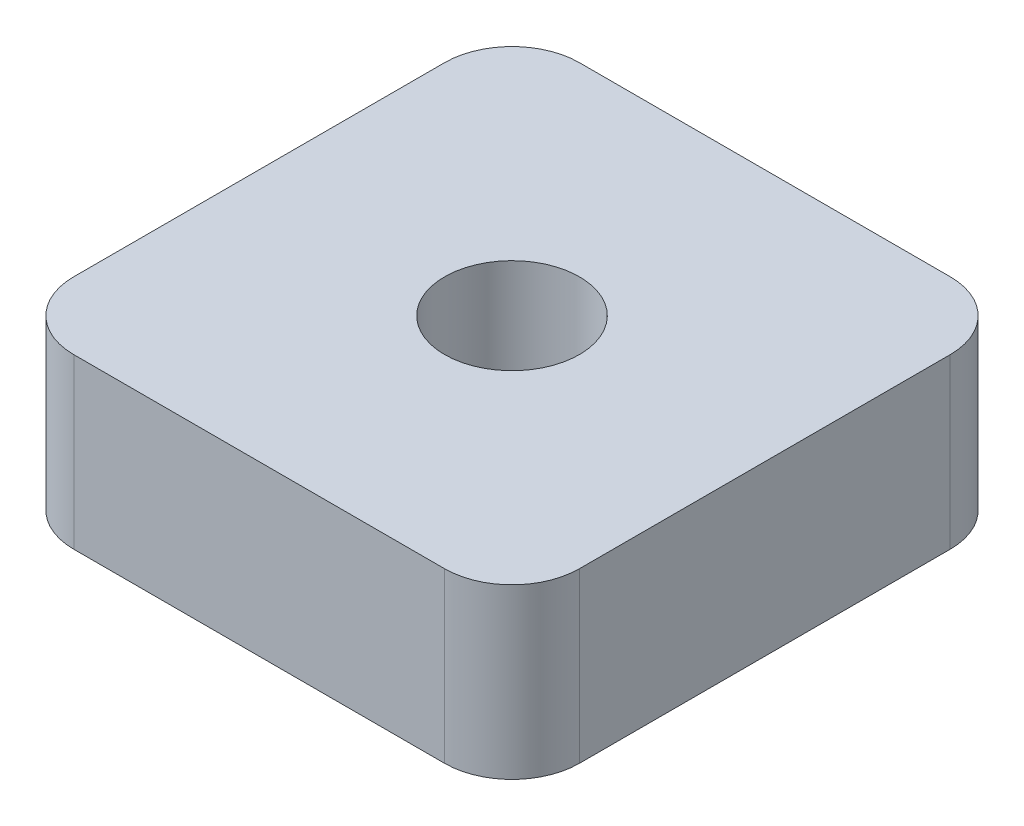
from build123d import *

# Parameters (mm, degrees)
SKETCH1_R           = 2
BOSS_EXTRUDE1_DEPTH = 5


with BuildPart() as part:
    # Sketch1 → Boss-Extrude1 (new body)
    with BuildSketch(Plane(origin=(0, 0, 0), x_dir=(1, 0, 0), z_dir=(0, 1, 0))):
        with BuildLine():
            Line((5.5, -7.5), (-5.5, -7.5))
            ThreePointArc((-5.5, -7.5), (-6.914213562, -6.914213562), (-7.5, -5.5))
            Line((-7.5, -5.5), (-7.5, 5.5))
            ThreePointArc((-7.5, 5.5), (-6.914213562, 6.914213562), (-5.5, 7.5))
            Line((-5.5, 7.5), (5.5, 7.5))
            ThreePointArc((5.5, 7.5), (6.914213562, 6.914213562), (7.5, 5.5))
            Line((7.5, 5.5), (7.5, -5.5))
            ThreePointArc((7.5, -5.5), (6.914213562, -6.914213562), (5.5, -7.5))
        make_face()
        Circle(SKETCH1_R, mode=Mode.SUBTRACT)
    extrude(amount=BOSS_EXTRUDE1_DEPTH)


solid = part.part
